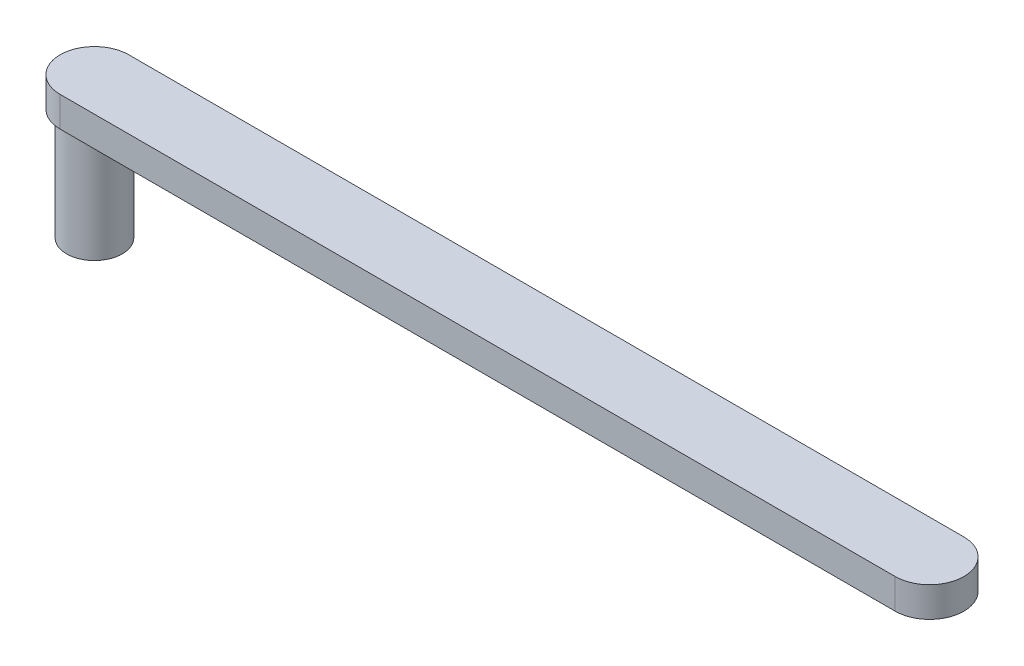
from build123d import *

# Parameters (mm, degrees)
SKETCH1_R           = 12.7
BOSS_EXTRUDE1_DEPTH = 50.8
BOSS_EXTRUDE2_DEPTH = 13.716


with BuildPart() as part:
    # Sketch1 → Boss-Extrude1 (new body)
    with BuildSketch(Plane(origin=(0, 0, 0), x_dir=(1, 0, 0), z_dir=(0, 1, 0))):
        Circle(SKETCH1_R)
    extrude(amount=BOSS_EXTRUDE1_DEPTH)

    # Sketch2 → Boss-Extrude2 (add)
    with BuildSketch(Plane(origin=(0, 50.8, 0), x_dir=(1, 0, 0), z_dir=(0, 1, 0))):
        with BuildLine():
            Line((0, 15.655268008), (381, 15.655268008))
            ThreePointArc((381, 15.655268008), (396.655268008, 0), (381, -15.655268008))
            Line((381, -15.655268008), (0, -15.655268008))
            ThreePointArc((0, -15.655268008), (-15.655268008, 0), (0, 15.655268008))
        make_face()
    extrude(amount=BOSS_EXTRUDE2_DEPTH)


solid = part.part
